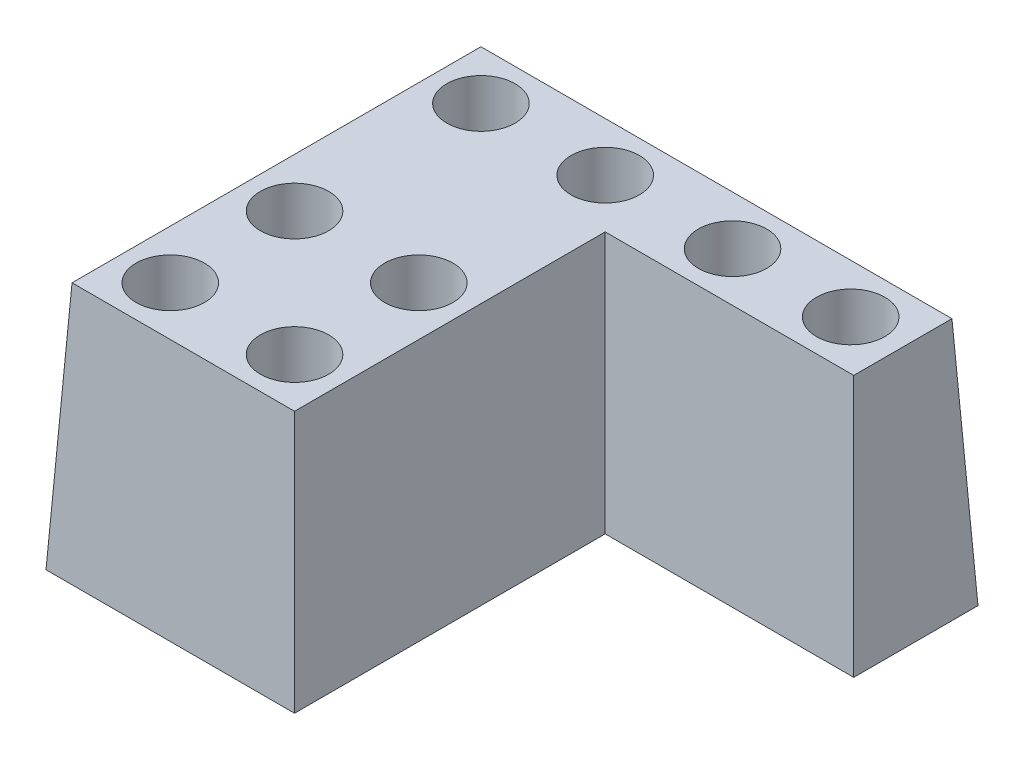
from build123d import *

# Parameters (mm, degrees)
BOSS_EXTRUDE1_DEPTH             = 40
BOSS_EXTRUDE1_TAPER             = 3
CBORE_FOR_M5_SBHCS1_D           = 5.5
CBORE_FOR_M5_SBHCS1_CBORE_D     = 11
CBORE_FOR_M5_SBHCS1_CBORE_DEPTH = 35


with BuildPart() as part:
    # Sketch1 → Boss-Extrude1 (new body)
    with BuildSketch(Plane(origin=(0, 0, 0), x_dir=(1, 0, 0), z_dir=(0, 1, 0))):
        Polygon((0, 0), (40, 0), (40, 50), (80, 50), (80, 70), (0, 70), align=None)
    extrude(amount=BOSS_EXTRUDE1_DEPTH, taper=BOSS_EXTRUDE1_TAPER)

    # CBORE for M5 SBHCS1 (through all)
    with Locations(Plane(origin=(0, 40, 0), x_dir=(1, 0, 0), z_dir=(0, 1, 0))):
        with Locations((69.508196721, 60), (30, 10), (10, 10), (10, 60), (50.491803279, 60), (30, 60), (10, 30), (30, 30)):
            CounterBoreHole(CBORE_FOR_M5_SBHCS1_D / 2, CBORE_FOR_M5_SBHCS1_CBORE_D / 2, CBORE_FOR_M5_SBHCS1_CBORE_DEPTH)


solid = part.part
